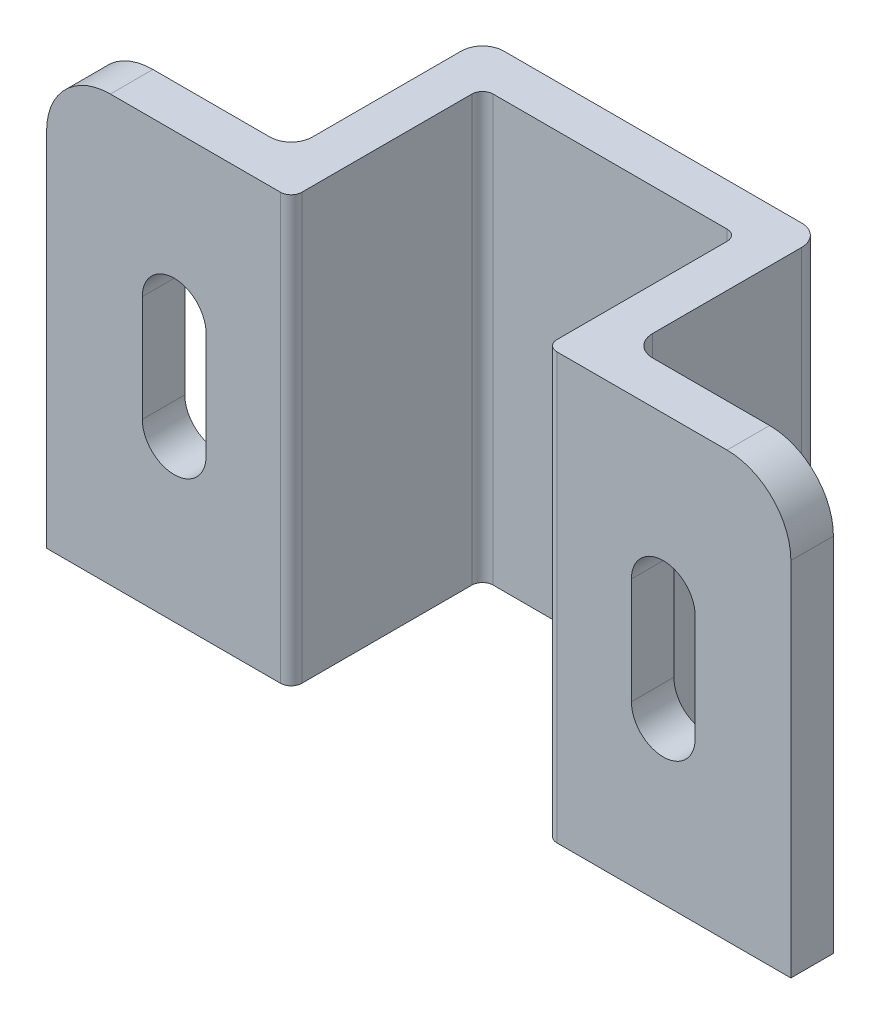
from build123d import *

# Parameters (mm, degrees)
SKETCH1_W           = 35
SKETCH1_H           = 20
BOSS_EXTRUDE1_DEPTH = 2
SKETCH4_W           = 11.5
SKETCH4_H           = 20
BOSS_EXTRUDE2_DEPTH = 9
SKETCH5_W           = 9.5
SKETCH5_H           = 9
CUT_EXTRUDE2_DEPTH  = 21
FILLET1_R           = 1
FILLET2_R           = 0.5
CUT_EXTRUDE3_DEPTH  = 12
FILLET3_R           = 3


with BuildPart() as part:
    # Sketch1 → Boss-Extrude1 (new body)
    with BuildSketch(Plane.XY):
        with Locations((17.5, 10)):
            Rectangle(SKETCH1_W, SKETCH1_H)
    extrude(amount=BOSS_EXTRUDE1_DEPTH)

    # Sketch4 → Boss-Extrude2 (add)
    with BuildSketch(Plane.XY.offset(2)):
        with Locations((5.75, 10)):
            Rectangle(SKETCH4_W, SKETCH4_H)
        with Locations((29.25, 10)):
            Rectangle(SKETCH4_W, SKETCH4_H)
    extrude(amount=BOSS_EXTRUDE2_DEPTH)

    # Sketch5 → Cut-Extrude2 (cut, through all)
    with BuildSketch(Plane(origin=(0, 20, 0), x_dir=(1, 0, 0), z_dir=(0, 1, 0))):
        with Locations((4.75, -4.5)):
            Rectangle(SKETCH5_W, SKETCH5_H)
        with Locations((30.25, -4.5)):
            Rectangle(SKETCH5_W, SKETCH5_H)
    extrude(amount=-CUT_EXTRUDE2_DEPTH, mode=Mode.SUBTRACT)

    # Fillet1
    fillet1_edges = [part.edges().sort_by_distance(p)[0] for p in [
        (9.5, 10, 0),
        (9.5, 10, 9),
        (25.5, 10, 9),
        (25.5, 10, 0),
    ]]
    fillet(fillet1_edges, radius=FILLET1_R)

    # Fillet2
    fillet2_edges = [part.edges().sort_by_distance(p)[0] for p in [
        (11.5, 10, 2),
        (11.5, 10, 11),
        (23.5, 10, 2),
        (23.5, 10, 11),
    ]]
    fillet(fillet2_edges, radius=FILLET2_R)

    # Sketch2 → Cut-Extrude3 (cut, through all)
    with BuildSketch(Plane.XY.offset(11)):
        with BuildLine():
            Line((7.5, 12.5), (7.5, 7.5))
            ThreePointArc((7.5, 7.5), (6, 6), (4.5, 7.5))
            Line((4.5, 7.5), (4.5, 12.5))
            ThreePointArc((4.5, 12.5), (6, 14), (7.5, 12.5))
        make_face()
        with BuildLine():
            Line((30.5, 12.5), (30.5, 7.5))
            ThreePointArc((30.5, 7.5), (29, 6), (27.5, 7.5))
            Line((27.5, 7.5), (27.5, 12.5))
            ThreePointArc((27.5, 12.5), (29, 14), (30.5, 12.5))
        make_face()
    extrude(amount=-CUT_EXTRUDE3_DEPTH, mode=Mode.SUBTRACT)

    # Fillet3
    fillet3_edges = [part.edges().sort_by_distance(p)[0] for p in [
        (0, 20, 10),
        (35, 20, 10),
    ]]
    fillet(fillet3_edges, radius=FILLET3_R)


solid = part.part
